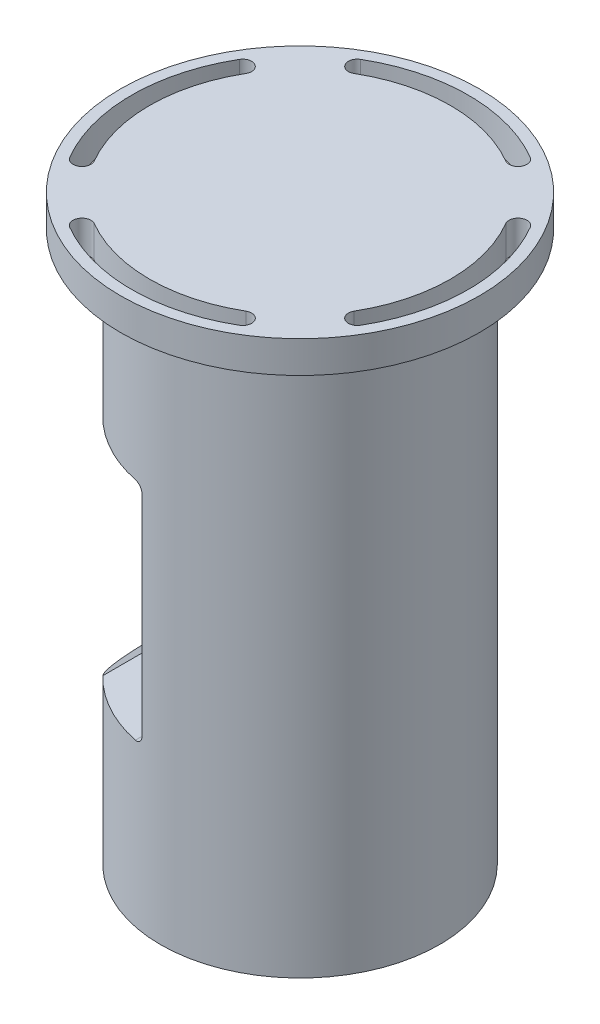
from build123d import *

# Parameters (mm, degrees)
CROQUIS1_R                = 35
SALIENTE_EXTRUIR1_DEPTH   = 138
CROQUIS2_R                = 45
SALIENTE_EXTRUIR2_DEPTH   = 8
CORTAR_EXTRUIR1_DEPTH     = 83.5
CORTAR_EXTRUIR2_DEPTH     = 167
TALADRO_ROSCADO_M41_D     = 3.3
TALADRO_ROSCADO_M41_DEPTH = 18
TALADRO_ROSCADO_M41_TIP   = 0.991420021


with BuildPart() as part:
    # Croquis1 → Saliente-Extruir1 (new body)
    with BuildSketch(Plane(origin=(0, 0, 0), x_dir=(1, 0, 0), z_dir=(0, 1, 0))):
        Circle(CROQUIS1_R)
    extrude(amount=SALIENTE_EXTRUIR1_DEPTH)

    # Croquis2 → Saliente-Extruir2 (add)
    with BuildSketch(Plane(origin=(0, 138, 0), x_dir=(1, 0, 0), z_dir=(0, 1, 0))):
        Circle(CROQUIS2_R)
    extrude(amount=SALIENTE_EXTRUIR2_DEPTH)

    # Croquis3 → Cortar-Revolución1 (revolve, cut)
    with BuildSketch(Plane.XY):
        Polygon((5, 0), (32.5, 0), (32.5, 22), (33.5, 22), (33.5, 25), (31, 25), (31, 113), (27.5, 113), (27.5, 128), (5, 141), align=None)
    revolve(axis=Axis((5, 141, 0), (0, -1, 0)), mode=Mode.SUBTRACT)

    # Croquis4 → Cortar-Extruir1 (cut, symmetric)
    with BuildSketch(Plane.XY):
        with BuildLine():
            Line((-35, 32.5), (-25.1, 40.6))
            Line((-25.1, 40.6), (-7, 40.6))
            ThreePointArc((-7, 40.6), (-5.585786438, 41.185786438), (-5, 42.6))
            Line((-5, 42.6), (-5, 95.2))
            ThreePointArc((-5, 95.2), (-5.585786438, 96.614213562), (-7, 97.2))
            Line((-7, 97.2), (-25.1, 97.2))
            Line((-25.1, 97.2), (-35, 105.3))
            Line((-35, 105.3), (-45, 105.3))
            Line((-45, 105.3), (-45, 32.5))
            Line((-45, 32.5), (-35, 32.5))
        make_face()
    extrude(amount=CORTAR_EXTRUIR1_DEPTH, both=True, mode=Mode.SUBTRACT)

    # Croquis5 → Cortar-Extruir2 (cut)
    with BuildSketch(Plane.XZ.offset(-138)):
        with BuildLine():
            ThreePointArc((-21.290820143, -36.493334702), (0, -42.25), (21.290820143, -36.493334702))
            ThreePointArc((21.290820143, -36.493334702), (22.10042151, -33.416072018), (19.023158826, -32.606470651))
            ThreePointArc((19.023158826, -32.606470651), (0, -37.75), (-19.023158826, -32.606470651))
            ThreePointArc((-19.023158826, -32.606470651), (-22.10042151, -33.416072018), (-21.290820143, -36.493334702))
        make_face()
        with BuildLine():
            ThreePointArc((36.493334702, -21.290820143), (42.25, 0), (36.493334702, 21.290820143))
            ThreePointArc((36.493334702, 21.290820143), (33.416072018, 22.10042151), (32.606470651, 19.023158826))
            ThreePointArc((32.606470651, 19.023158826), (37.75, 0), (32.606470651, -19.023158826))
            ThreePointArc((32.606470651, -19.023158826), (33.416072018, -22.10042151), (36.493334702, -21.290820143))
        make_face()
        with BuildLine():
            ThreePointArc((21.290820143, 36.493334702), (0, 42.25), (-21.290820143, 36.493334702))
            ThreePointArc((-21.290820143, 36.493334702), (-22.10042151, 33.416072018), (-19.023158826, 32.606470651))
            ThreePointArc((-19.023158826, 32.606470651), (0, 37.75), (19.023158826, 32.606470651))
            ThreePointArc((19.023158826, 32.606470651), (22.10042151, 33.416072018), (21.290820143, 36.493334702))
        make_face()
        with BuildLine():
            ThreePointArc((-36.493334702, 21.290820143), (-42.25, 0), (-36.493334702, -21.290820143))
            ThreePointArc((-36.493334702, -21.290820143), (-33.416072018, -22.10042151), (-32.606470651, -19.023158826))
            ThreePointArc((-32.606470651, -19.023158826), (-37.75, 0), (-32.606470651, 19.023158826))
            ThreePointArc((-32.606470651, 19.023158826), (-33.416072018, 22.10042151), (-36.493334702, 21.290820143))
        make_face()
    extrude(amount=-CORTAR_EXTRUIR2_DEPTH, mode=Mode.SUBTRACT)

    # Taladro roscado M41
    with Locations(Plane.XZ):
        with Locations((-30, 0)):
            Hole(TALADRO_ROSCADO_M41_D / 2, depth=TALADRO_ROSCADO_M41_DEPTH)
            with Locations((0, 0, -(TALADRO_ROSCADO_M41_DEPTH + TALADRO_ROSCADO_M41_TIP / 2))):  # 118° drill point
                Cone(0, TALADRO_ROSCADO_M41_D / 2, TALADRO_ROSCADO_M41_TIP, mode=Mode.SUBTRACT)


solid = part.part
